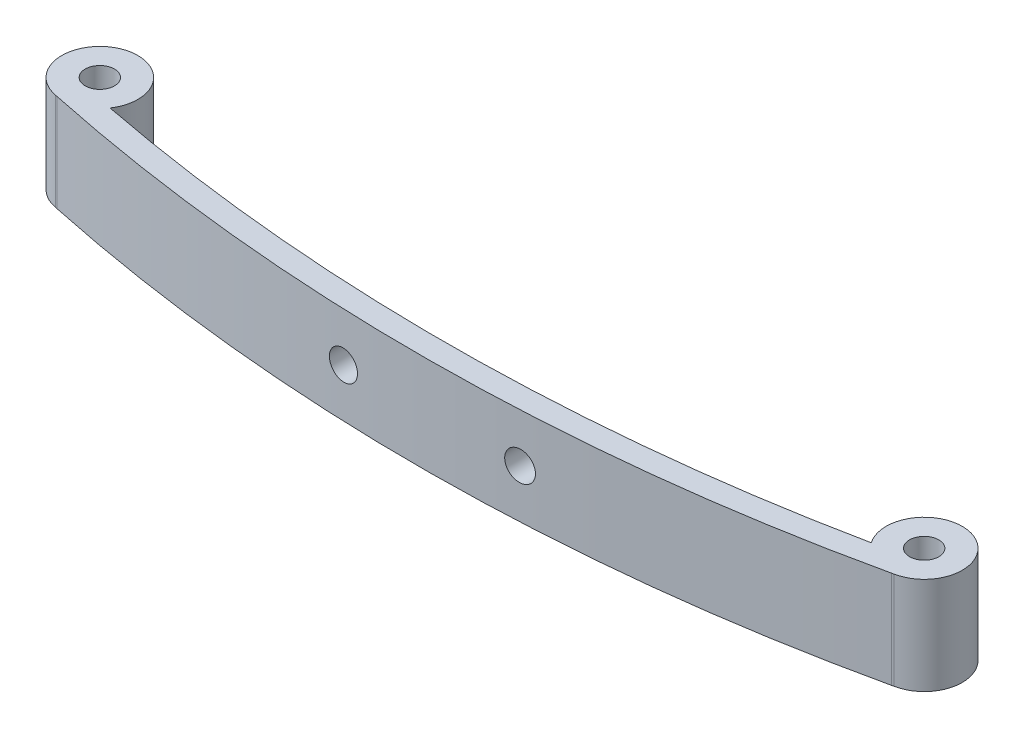
from build123d import *

# Parameters (mm, degrees)
SKETCH1_R               = 1.25
BOSS_EXTRUDE1_DEPTH     = 8.3
SKETCH2_R               = 1.25
CUT_EXTRUDE1_DEPTH      = 3.700074126
CUT_EXTRUDE1_DEPTH_BACK = 8.770575704


with BuildPart() as part:
    # Sketch1 → Boss-Extrude1 (new body)
    with BuildSketch(Plane(origin=(0, 0, 0), x_dir=(1, 0, 0), z_dir=(0, 1, 0))):
        with BuildLine():
            Line((35.434172296, 1.287491613), (35.622727971, 1.3307936))
            ThreePointArc((35.622727971, 1.3307936), (36.223294794, 7.531563888), (32.32905872, 2.668935167))
            ThreePointArc((32.32905872, 2.668935167), (0.027157554, -0.697665471), (-32.309217612, 2.319893124))
            ThreePointArc((-32.309217612, 2.319893124), (-36.261610619, 7.13771657), (-35.575715837, 0.943979283))
            Line((-35.575715837, 0.943979283), (-35.413230424, 0.907951956))
            ThreePointArc((-35.413230424, 0.907951956), (0.030803418, -2.69767479), (35.434172296, 1.287491613))
        make_face()
        with Locations((-35, 4.142580739)):
            Circle(SKETCH1_R, mode=Mode.SUBTRACT)
        with Locations((35, 4.520575704)):
            Circle(SKETCH1_R, mode=Mode.SUBTRACT)
    extrude(amount=BOSS_EXTRUDE1_DEPTH)

    # Sketch2 → Cut-Extrude1 (cut, two sides)
    with BuildSketch(Plane.XY) as cut_extrude1_sk:
        with Locations((7.505235468, 4.15)):
            Circle(SKETCH2_R)
        with Locations((-7.494764532, 4.15)):
            Circle(SKETCH2_R)
    extrude(amount=CUT_EXTRUDE1_DEPTH, mode=Mode.SUBTRACT)
    extrude(cut_extrude1_sk.sketch, amount=-CUT_EXTRUDE1_DEPTH_BACK, mode=Mode.SUBTRACT)


solid = part.part
